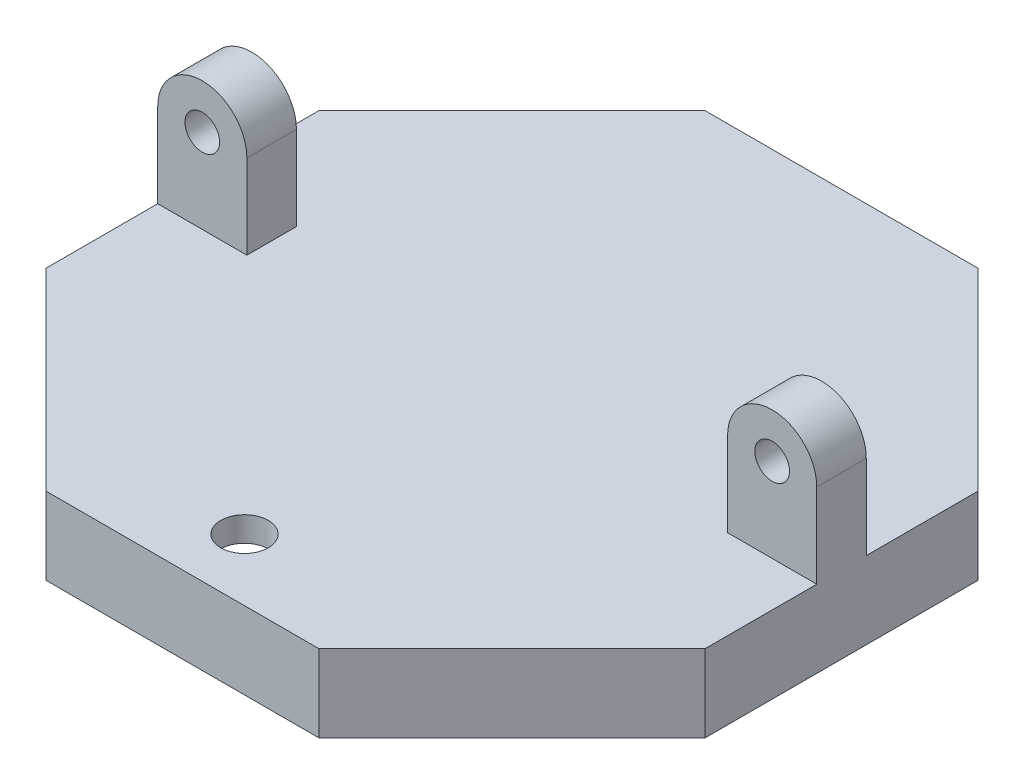
from build123d import *

# Parameters (mm, degrees)
EXTRUDE_1_DEPTH     = 2.5
EXTRUDE_2_DEPTH     = 5.3
CUT_EXTRUDE_1_DEPTH = 1
SKETCH_6_R          = 4.015
EXTRUDE_4_DEPTH     = 4
SKETCH_7_R          = 2.4
CUT_EXTRUDE_3_DEPTH = 48.67861563
SKETCH_8_W          = 9
SKETCH_8_H          = 5
EXTRUDE_5_DEPTH     = 8.5
SKETCH_9_W          = 4.5
SKETCH_9_H          = 5
SKETCH_10_R         = 1.75
CUT_EXTRUDE_4_DEPTH = 52.236790534


with BuildPart() as part:
    # 스케치1 → 보스-돌출1 (new body)
    with BuildSketch(Plane(origin=(0, 0, 0), x_dir=(1, 0, 0), z_dir=(0, 1, 0))):
        Polygon((13.776603565, 33.25966317), (-13.776603565, 33.25966317), (-33.25966317, 13.776603565), (-33.25966317, -13.776603565), (-13.776603565, -33.25966317), (13.776603565, -33.25966317), (33.25966317, -13.776603565), (33.25966317, 13.776603565), align=None)
        Polygon((-13.27954729, 32.05966317), (-32.05966317, 13.27954729), (-32.05966317, -13.27954729), (-13.27954729, -32.05966317), (13.27954729, -32.05966317), (32.05966317, -13.27954729), (32.05966317, 13.27954729), (13.27954729, 32.05966317), align=None, mode=Mode.SUBTRACT)
        Polygon((13.27954729, 32.05966317), (-13.27954729, 32.05966317), (-32.05966317, 13.27954729), (-32.05966317, -13.27954729), (-13.27954729, -32.05966317), (13.27954729, -32.05966317), (32.05966317, -13.27954729), (32.05966317, 13.27954729), align=None)
    extrude(amount=EXTRUDE_1_DEPTH)

    # 스케치2 → 보스-돌출2 (add)
    with BuildSketch(Plane.XZ):
        Polygon((-33.25966317, -13.776603565), (-13.776603565, -33.25966317), (13.776603565, -33.25966317), (33.25966317, -13.776603565), (33.25966317, 13.776603565), (13.776603565, 33.25966317), (-13.776603565, 33.25966317), (-33.25966317, 13.776603565), align=None)
        Polygon((-32.05966317, -13.27954729), (-13.27954729, -32.05966317), (13.27954729, -32.05966317), (32.05966317, -13.27954729), (32.05966317, 13.27954729), (13.27954729, 32.05966317), (-13.27954729, 32.05966317), (-32.05966317, 13.27954729), align=None, mode=Mode.SUBTRACT)
        Polygon((-32.05966317, 13.27954729), (-32.05966317, -13.27954729), (-13.27954729, -32.05966317), (13.27954729, -32.05966317), (32.05966317, -13.27954729), (32.05966317, 13.27954729), (13.27954729, 32.05966317), (-13.27954729, 32.05966317), align=None)
        Polygon((-30.85966317, -12.782491015), (-12.782491015, -30.85966317), (12.782491015, -30.85966317), (30.85966317, -12.782491015), (30.85966317, 12.782491015), (12.782491015, 30.85966317), (-12.782491015, 30.85966317), (-30.85966317, 12.782491015), align=None, mode=Mode.SUBTRACT)
        Polygon((-30.85966317, 12.782491015), (-30.85966317, -12.782491015), (-12.782491015, -30.85966317), (12.782491015, -30.85966317), (30.85966317, -12.782491015), (30.85966317, 12.782491015), (12.782491015, 30.85966317), (-12.782491015, 30.85966317), align=None)
        Polygon((-29.65966317, -12.285434741), (-12.285434741, -29.65966317), (12.285434741, -29.65966317), (29.65966317, -12.285434741), (29.65966317, 12.285434741), (12.285434741, 29.65966317), (-12.285434741, 29.65966317), (-29.65966317, 12.285434741), align=None, mode=Mode.SUBTRACT)
    extrude(amount=EXTRUDE_2_DEPTH)

    # 스케치3 → 컷-돌출1 (cut)
    with BuildSketch(Plane.XZ.offset(5.3)):
        Polygon((-32.05966317, -13.27954729), (-13.27954729, -32.05966317), (13.27954729, -32.05966317), (32.05966317, -13.27954729), (32.05966317, 13.27954729), (13.27954729, 32.05966317), (-13.27954729, 32.05966317), (-32.05966317, 13.27954729), align=None)
        Polygon((-30.85966317, -12.782491015), (-12.782491015, -30.85966317), (12.782491015, -30.85966317), (30.85966317, -12.782491015), (30.85966317, 12.782491015), (12.782491015, 30.85966317), (-12.782491015, 30.85966317), (-30.85966317, 12.782491015), align=None, mode=Mode.SUBTRACT)
    extrude(amount=-CUT_EXTRUDE_1_DEPTH, mode=Mode.SUBTRACT)

    # 스케치6 → 보스-돌출4 (add)
    with BuildSketch(Plane.XZ):
        with Locations(Location((0, 0, 0), (0, 0, 90))):
            Circle(SKETCH_6_R)
    extrude(amount=EXTRUDE_4_DEPTH)

    # 스케치7 → 컷-돌출3 (cut, through all)
    with BuildSketch(Plane(origin=(0, 2.5, 0), x_dir=(1, 0, 0), z_dir=(0, 1, 0))):
        with Locations(Location((0, -27, 0), (0, 0, 270))):
            Circle(SKETCH_7_R)
    extrude(amount=-CUT_EXTRUDE_3_DEPTH, mode=Mode.SUBTRACT)

    # 스케치8 → 보스-돌출5 (add)
    with BuildSketch(Plane(origin=(0, 2.5, 0), x_dir=(1, 0, 0), z_dir=(0, 1, 0))):
        with Locations((-28.75966317, 0)):
            Rectangle(SKETCH_8_W, SKETCH_8_H)
    extrude_5 = extrude(amount=EXTRUDE_5_DEPTH)

    # 스케치9 → 회전1 (revolve)
    with BuildSketch(Plane(origin=(0, 11, 0), x_dir=(1, 0, 0), z_dir=(0, 1, 0))):
        with Locations((-31.00966317, 0)):
            Rectangle(SKETCH_9_W, SKETCH_9_H)
    revolve_1 = revolve(axis=Axis((-28.75966317, 11, -5.508751215), (0, 0, 1)))

    # 스케치10 → 컷-돌출4 (cut, through all)
    with BuildSketch(Plane.XY.offset(2.5)):
        with Locations((-28.75966317, 11)):
            Circle(SKETCH_10_R)
    cut_extrude_4 = extrude(amount=-CUT_EXTRUDE_4_DEPTH, mode=Mode.SUBTRACT)

    # 대칭 복사1: 보스-돌출5, 회전1, 컷-돌출4 across plane
    add(extrude_5.mirror(Plane(origin=(0, 0, 0), x_dir=(0, 0, 1), z_dir=(1, 0, 0))))
    add(revolve_1.mirror(Plane(origin=(0, 0, 0), x_dir=(0, 0, 1), z_dir=(1, 0, 0))))
    add(cut_extrude_4.mirror(Plane(origin=(0, 0, 0), x_dir=(0, 0, 1), z_dir=(1, 0, 0))), mode=Mode.SUBTRACT)


solid = part.part
